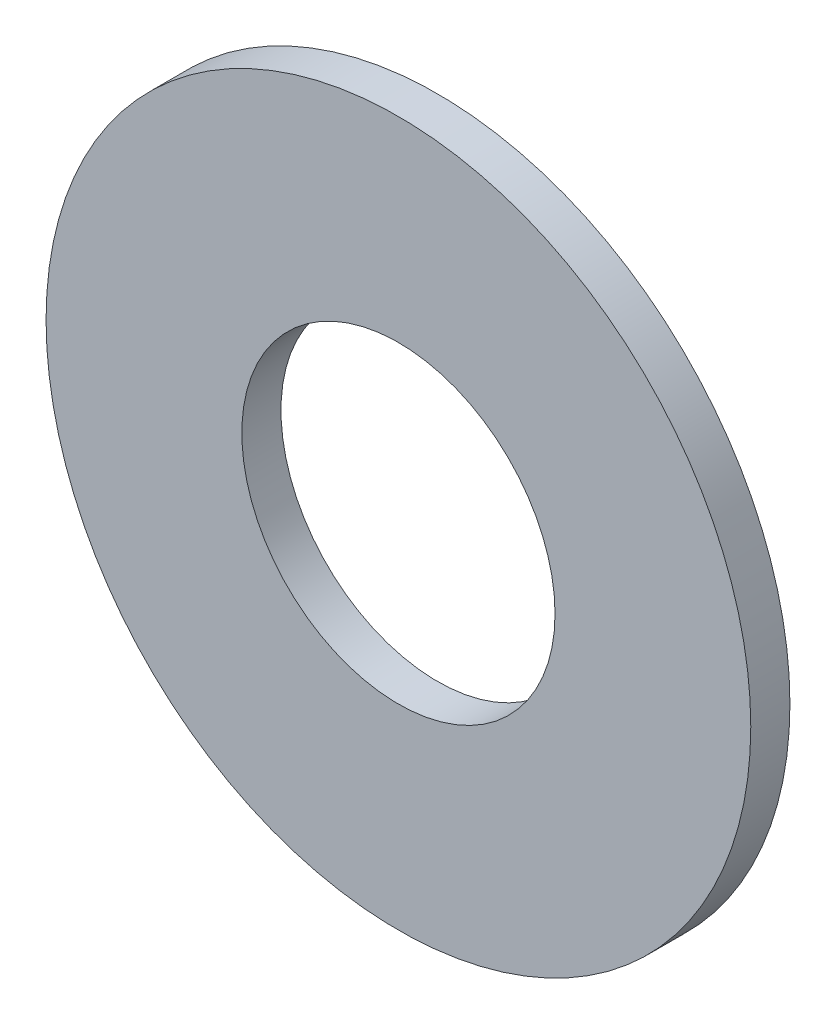
from build123d import *

# Parameters (mm, degrees)
CROQUIS1_R              = 9
CROQUIS1_R_2            = 4
SALIENTE_EXTRUIR1_DEPTH = 1


with BuildPart() as part:
    # Croquis1 → Saliente-Extruir1 (new body)
    with BuildSketch(Plane.XY):
        Circle(CROQUIS1_R)
        Circle(CROQUIS1_R_2, mode=Mode.SUBTRACT)
    extrude(amount=SALIENTE_EXTRUIR1_DEPTH)


solid = part.part
